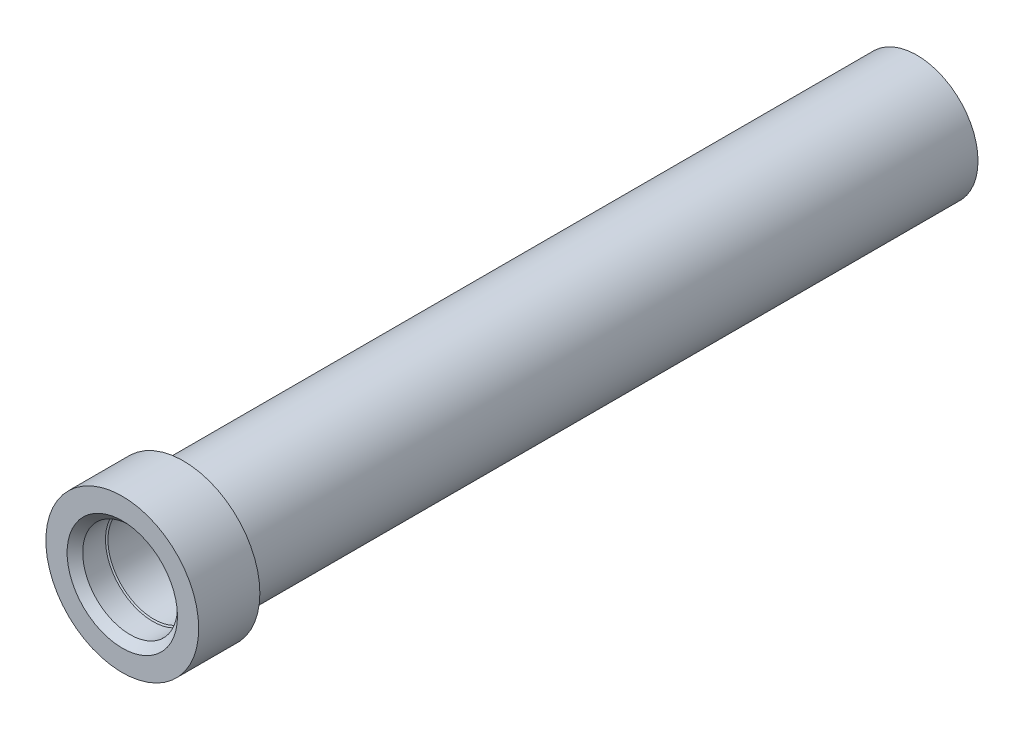
from build123d import *

# Parameters (mm, degrees)
SKETCH4_R                    = 5
CUT_EXTRUDE1_DEPTH           = 119.95
SKETCH5_R                    = 7.5
CUT_EXTRUDE2_DEPTH           = 80
M18_TAPPED_HOLE1_D           = 15.5
M18_TAPPED_HOLE1_DEPTH       = 5
M18_TAPPED_HOLE1_CSINK_D     = 18.05
M18_TAPPED_HOLE1_CSINK_ANGLE = 90
M18_TAPPED_HOLE1_TIP         = 4.656669797


with BuildPart() as part:
    # Sketch3 → Revolve2 (revolve)
    with BuildSketch(Plane(origin=(0, 0, 0), x_dir=(0, 0, -1), z_dir=(1, 0, 0))):
        Polygon((0, 12.5), (10, 12.5), (10, 10), (129.95, 10), (129.95, 0), (0, 0), align=None)
    revolve(axis=Axis((0, 0, 0), (0, 0, -1)))

    # Sketch4 → Cut-Extrude1 (cut)
    with BuildSketch(Plane(origin=(0, 0, -129.95), x_dir=(-1, 0, 0), z_dir=(0, 0, -1))):
        Circle(SKETCH4_R)
    extrude(amount=-CUT_EXTRUDE1_DEPTH, mode=Mode.SUBTRACT)

    # Sketch5 → Cut-Extrude2 (cut)
    with BuildSketch(Plane.XY):
        Circle(SKETCH5_R)
    extrude(amount=-CUT_EXTRUDE2_DEPTH, mode=Mode.SUBTRACT)

    # M18 Tapped Hole1
    with Locations(Plane.XY):
        with Locations((0, 0)):
            CounterSinkHole(M18_TAPPED_HOLE1_D / 2, M18_TAPPED_HOLE1_CSINK_D / 2, depth=M18_TAPPED_HOLE1_DEPTH, counter_sink_angle=M18_TAPPED_HOLE1_CSINK_ANGLE)
            with Locations((0, 0, -(M18_TAPPED_HOLE1_DEPTH + M18_TAPPED_HOLE1_TIP / 2))):  # 118° drill point
                Cone(0, M18_TAPPED_HOLE1_D / 2, M18_TAPPED_HOLE1_TIP, mode=Mode.SUBTRACT)


solid = part.part
